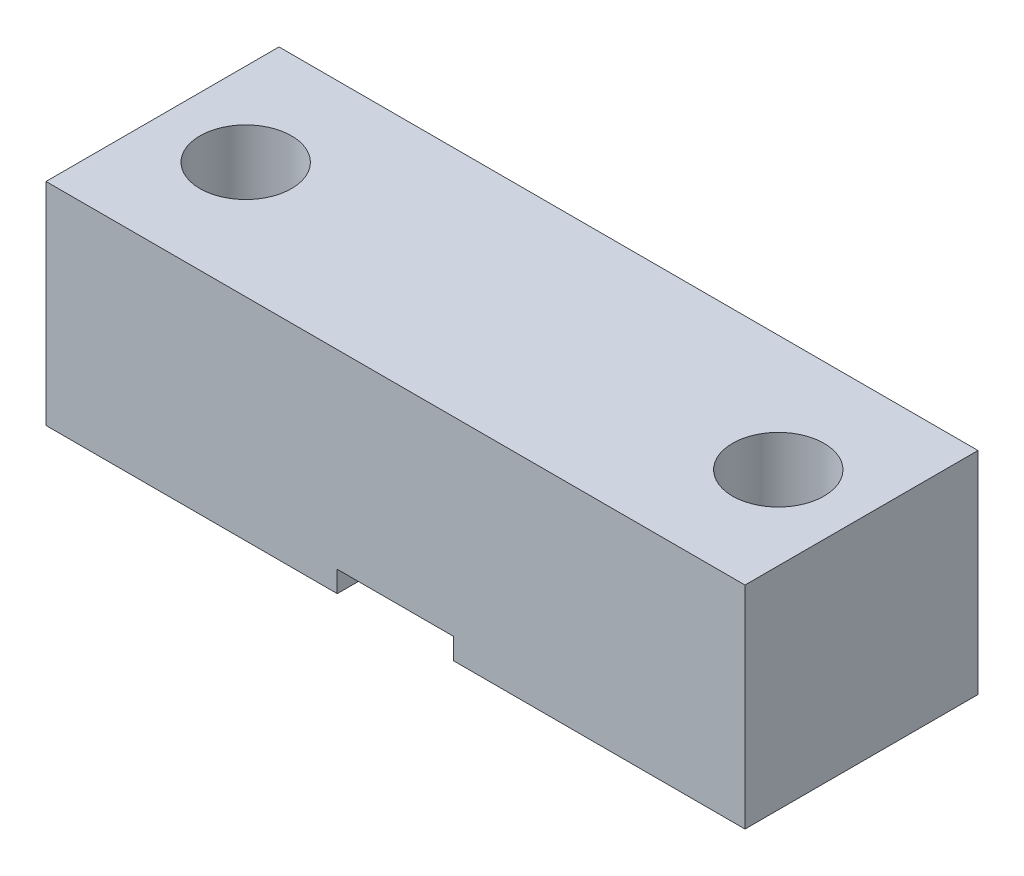
from build123d import *

# Parameters (mm, degrees)
SKETCH1_W           = 42
SKETCH1_H           = 14
SKETCH1_R           = 2.75
BOSS_EXTRUDE1_DEPTH = 12.7
SKETCH2_W           = 7
SKETCH2_H           = 1.27
CUT_EXTRUDE1_DEPTH  = 14


with BuildPart() as part:
    # Sketch1 → Boss-Extrude1 (new body)
    with BuildSketch(Plane(origin=(0, 0, 0), x_dir=(1, 0, 0), z_dir=(0, 1, 0))):
        Rectangle(SKETCH1_W, SKETCH1_H)
        with Locations((-16, 0)):
            Circle(SKETCH1_R, mode=Mode.SUBTRACT)
        with Locations((16, 0)):
            Circle(SKETCH1_R, mode=Mode.SUBTRACT)
    extrude(amount=BOSS_EXTRUDE1_DEPTH)

    # Sketch2 → Cut-Extrude1 (cut)
    with BuildSketch(Plane.XY.offset(7)):
        with Locations((0, 0.635)):
            Rectangle(SKETCH2_W, SKETCH2_H)
    extrude(amount=-CUT_EXTRUDE1_DEPTH, mode=Mode.SUBTRACT)


solid = part.part
